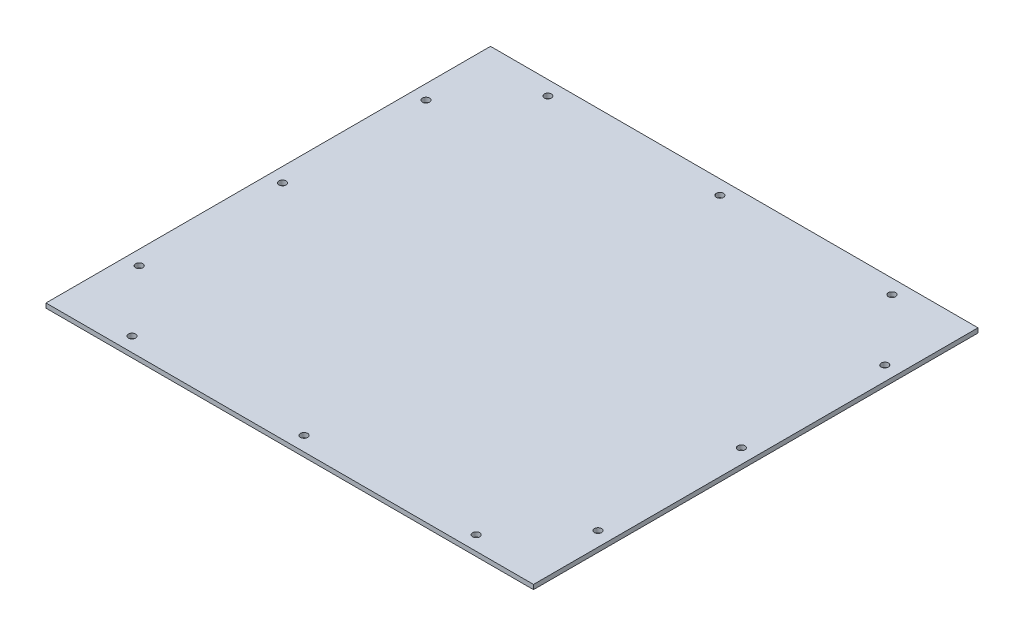
from build123d import *

# Parameters (mm, degrees)
SKETCH1_W           = 340
SKETCH1_H           = 310
BOSS_EXTRUDE1_DEPTH = 3.175
SKETCH2_R           = 2.5
CUT_EXTRUDE1_DEPTH  = 3.175


with BuildPart() as part:
    # Sketch1 → Boss-Extrude1 (new body)
    with BuildSketch(Plane(origin=(0, 0, 0), x_dir=(1, 0, 0), z_dir=(0, 1, 0))):
        with Locations((170, 155)):
            Rectangle(SKETCH1_W, SKETCH1_H)
    extrude(amount=BOSS_EXTRUDE1_DEPTH)

    # Sketch2 → Cut-Extrude1 (cut)
    with BuildSketch(Plane(origin=(0, 3.175, 0), x_dir=(1, 0, 0), z_dir=(0, 1, 0))):
        with Locations((10, 155)):
            Circle(SKETCH2_R)
        with Locations((10, 255)):
            Circle(SKETCH2_R)
        with Locations((10, 55)):
            Circle(SKETCH2_R)
        with Locations((50, 10)):
            Circle(SKETCH2_R)
        with Locations((170, 10)):
            Circle(SKETCH2_R)
        with Locations((290, 10)):
            Circle(SKETCH2_R)
        with Locations((330, 55)):
            Circle(SKETCH2_R)
        with Locations((330, 155)):
            Circle(SKETCH2_R)
        with Locations((330, 255)):
            Circle(SKETCH2_R)
        with Locations((290, 300)):
            Circle(SKETCH2_R)
        with Locations((170, 300)):
            Circle(SKETCH2_R)
        with Locations((50, 300)):
            Circle(SKETCH2_R)
    extrude(amount=-CUT_EXTRUDE1_DEPTH, mode=Mode.SUBTRACT)


solid = part.part
